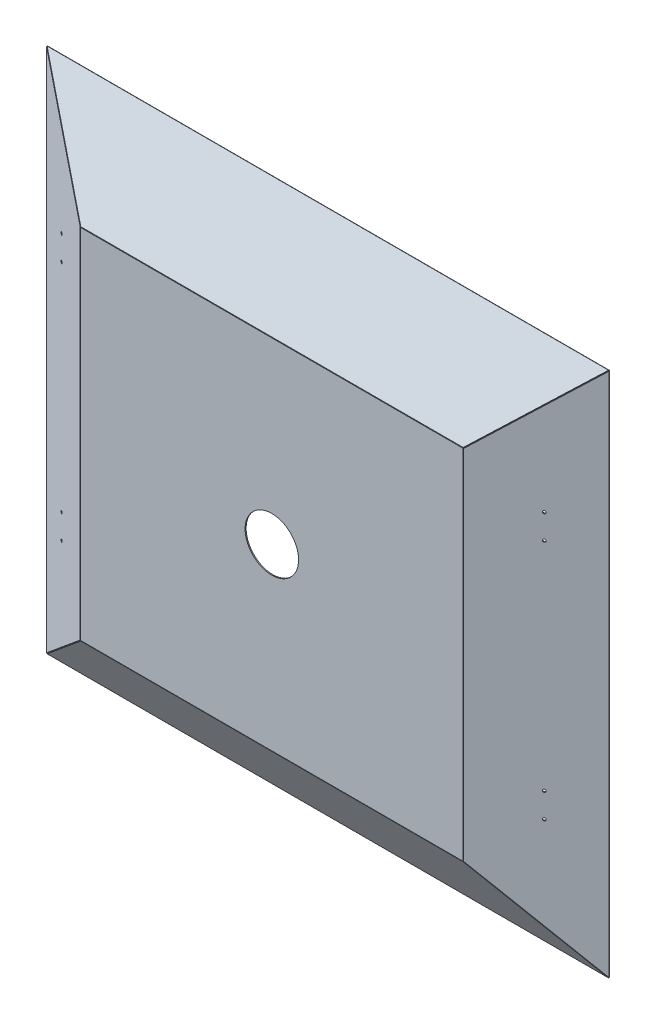
from build123d import *

# Parameters (mm, degrees)
BOSS_EXTRUDE1_DEPTH = 3
BOSS_EXTRUDE2_DEPTH = 3
BOSS_EXTRUDE3_DEPTH = 3
BOSS_EXTRUDE4_DEPTH = 3
SKETCH7_W           = 1101.2481203
SKETCH7_H           = 1030
BOSS_EXTRUDE5_DEPTH = 3
SKETCH9_R           = 4
CUT_EXTRUDE2_DEPTH  = 1319.156436785
SKETCH10_R          = 4
CUT_EXTRUDE3_DEPTH  = 1319.156436785
SKETCH11_R          = 77
CUT_EXTRUDE4_DEPTH  = 1122.504200496


with BuildPart() as part:
    # Sketch3 → Boss-Extrude1 (new body)
    with BuildSketch(Plane(origin=(0, -204.615384615, 306.923076923), x_dir=(1, 0, 0), z_dir=(0, -0.554700196225229, 0.8320502943378437))):
        Polygon((-550.62406015, -373.035881961), (550.62406015, -373.035881961), (711, -553.313445735), (808.609699533, -663.035881961), (-808.609699533, -663.035881961), (-711, -553.313445735), align=None)
    extrude(amount=BOSS_EXTRUDE1_DEPTH)


with BuildPart() as body_2:
    # Sketch4 → Boss-Extrude2 (new body)
    with BuildSketch(Plane(origin=(-199.04568884, 0, 319.221394207), x_dir=(-0.8485565730164447, 0, -0.5291046610932351), z_dir=(0.5291046610932351, 0, -0.8485565730164447))):
        Polygon((414.325199392, -515), (414.325199392, 515), (718.354002641, 756.294585358), (718.354002641, -756.294585358), align=None)
    extrude(amount=-BOSS_EXTRUDE2_DEPTH)

    # Sketch10 → Cut-Extrude3 (cut, through all)
    with BuildSketch(Plane(origin=(-199.04568884, 0, 319.221394207), x_dir=(-0.8485565730164447, 0, -0.5291046610932351), z_dir=(0.5291046610932351, 0, -0.8485565730164447))):
        with Locations((582.525895377, -383)):
            Circle(SKETCH10_R)
        with Locations((582.525895377, -312)):
            Circle(SKETCH10_R)
        with Locations((582.525895377, 312)):
            Circle(SKETCH10_R)
        with Locations((582.525895377, 383)):
            Circle(SKETCH10_R)
    extrude(amount=-CUT_EXTRUDE3_DEPTH, mode=Mode.SUBTRACT)


with BuildPart() as body_3:
    # Sketch5 → Boss-Extrude3 (new body)
    with BuildSketch(Plane(origin=(199.04568884, 0, 319.221394207), x_dir=(0.8485565730164449, 0, -0.5291046610932348), z_dir=(0.5291046610932347, 0, 0.8485565730164448))):
        Polygon((414.325199392, -515), (414.325199392, 515), (718.354002641, 756.294585358), (718.354002641, -756.294585358), align=None)
    extrude(amount=BOSS_EXTRUDE3_DEPTH)

    # Sketch9 → Cut-Extrude2 (cut, through all)
    with BuildSketch(Plane(origin=(199.04568884, 0, 319.221394207), x_dir=(-0.8485565730164449, 0, 0.5291046610932348), z_dir=(-0.5291046610932347, 0, -0.8485565730164448))):
        with Locations((-582.525895377, 383)):
            Circle(SKETCH9_R)
        with Locations((-582.525895377, 312)):
            Circle(SKETCH9_R)
        with Locations((-582.525895377, -312)):
            Circle(SKETCH9_R)
        with Locations((-582.525895377, -383)):
            Circle(SKETCH9_R)
    extrude(amount=-CUT_EXTRUDE2_DEPTH, mode=Mode.SUBTRACT)


with BuildPart() as body_4:
    # Sketch6 → Boss-Extrude4 (new body)
    with BuildSketch(Plane(origin=(0, 204.615384615, 306.923076923), x_dir=(-1, 0, 0), z_dir=(0, -0.554700196225229, -0.8320502943378437))):
        Polygon((-550.62406015, 373.035881961), (550.62406015, 373.035881961), (808.609699533, 663.035881961), (-808.609699533, 663.035881961), align=None)
    extrude(amount=-BOSS_EXTRUDE4_DEPTH)


with BuildPart() as body_5:
    # Sketch7 → Boss-Extrude5 (new body)
    with BuildSketch(Plane.XY.offset(100)):
        Rectangle(SKETCH7_W, SKETCH7_H)
    extrude(amount=BOSS_EXTRUDE5_DEPTH)

    # Sketch11 → Cut-Extrude4 (cut, through all)
    with BuildSketch(Plane.XY.offset(103)):
        Circle(SKETCH11_R)
    extrude(amount=-CUT_EXTRUDE4_DEPTH, mode=Mode.SUBTRACT)


solid = Compound([part.part, body_2.part, body_3.part, body_4.part, body_5.part])
